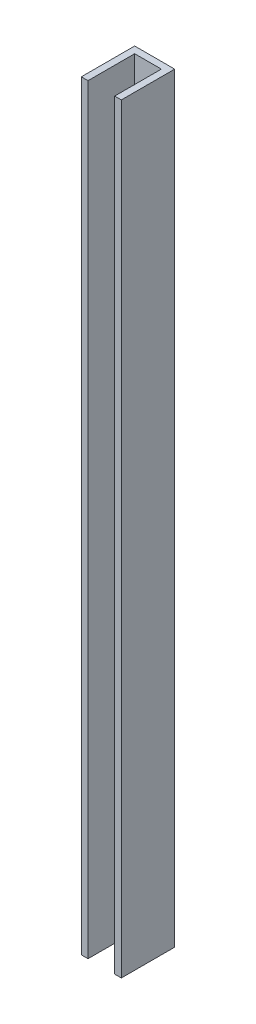
from build123d import *

# Parameters (mm, degrees)
BOSS_EXTRUDE1_DEPTH = 361.95


with BuildPart() as part:
    # Sketch1 → Boss-Extrude1 (new body)
    with BuildSketch(Plane(origin=(0, 0, 0), x_dir=(1, 0, 0), z_dir=(0, 1, 0))):
        Polygon((0, 0), (0, 25.4), (19.05, 25.4), (19.05, 0), (15.875, 0), (15.875, 22.225), (3.175, 22.225), (3.175, 0), align=None)
    extrude(amount=BOSS_EXTRUDE1_DEPTH)


solid = part.part
